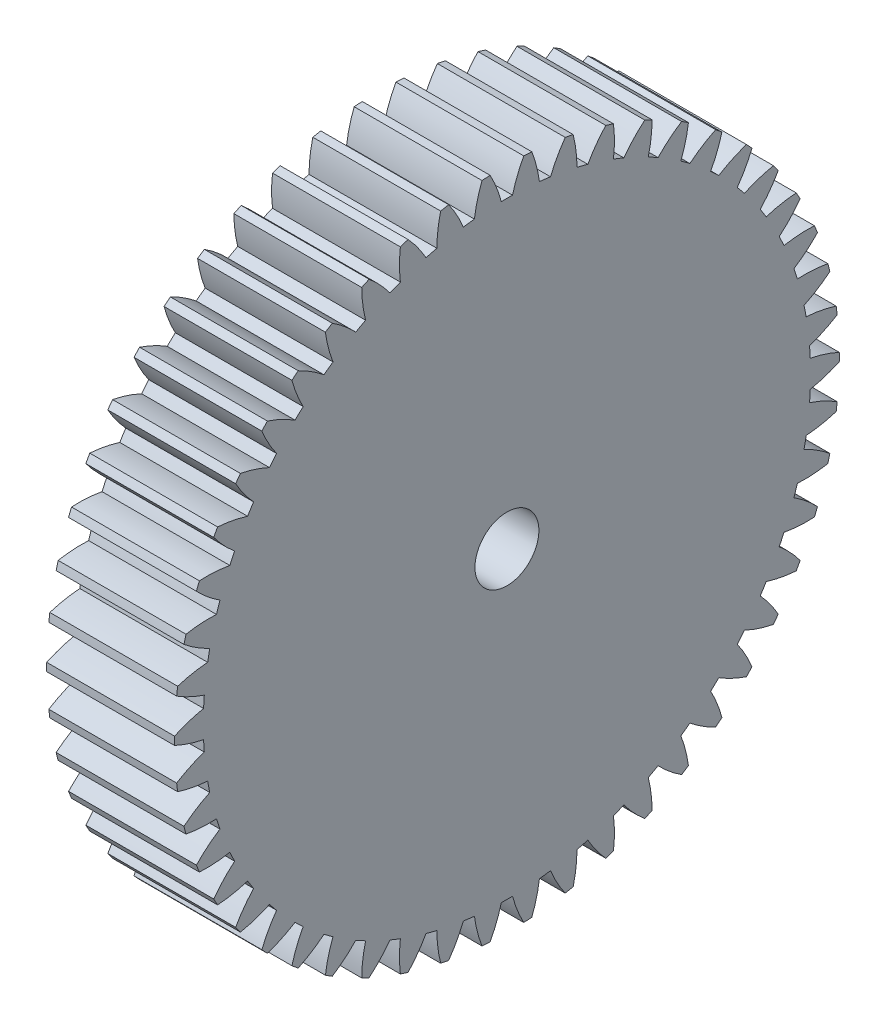
from build123d import *

# Parameters (mm, degrees)
BASPROSKE_W     = 10
BASPROSKE_H     = 26
TOOTHCUT_DEPTH  = 39.105117767
TEETHCUTS_COUNT = 50
TEETHCUTS_ANGLE = 352.8
BORSKE_R        = 2.5
BORE_DEPTH      = 50.0000508


with BuildPart() as part:
    # BasProSke → Base-Revolve (revolve)
    with BuildSketch(Plane(origin=(0, 0, 0), x_dir=(1, 0, 0), z_dir=(0, 1, 0)), mode=Mode.PRIVATE) as base_revolve_sk:
        with Locations((5, 13)):
            Rectangle(BASPROSKE_W, BASPROSKE_H)
    revolve(base_revolve_sk.sketch.rotate(Axis((-10, 0, 0), (1, 0, 0)), 180), axis=Axis((-10, 0, 0), (1, 0, 0)))

    # TooCutSke → ToothCut (cut, through all)
    with BuildSketch(Plane(origin=(0, 0, 0), x_dir=(0, 0, -1), z_dir=(1, 0, 0))):
        with BuildLine():
            ThreePointArc((0.437663408, 23.744966872), (0, 23.749), (-0.437663408, 23.744966872))
            ThreePointArc((-0.437663408, 23.744966872), (-0.815428123, 24.895236298), (-1.329433358, 25.991422664))
            ThreePointArc((-1.329433358, 25.991422664), (0, 26.0254), (1.329433358, 25.991422664))
            ThreePointArc((1.329433358, 25.991422664), (0.815428123, 24.895236298), (0.437663408, 23.744966872))
        make_face()
    toothcut = extrude(amount=TOOTHCUT_DEPTH, mode=Mode.SUBTRACT)

    # TeethCuts: ToothCut ×50 about axis
    teethcuts_axis = Axis((-10, 0, 0), (1, 0, 0))
    for i in range(1, TEETHCUTS_COUNT):
        add(toothcut.rotate(teethcuts_axis, i * TEETHCUTS_ANGLE / (TEETHCUTS_COUNT - 1)), mode=Mode.SUBTRACT)

    # BorSke → Bore (cut, symmetric)
    with BuildSketch(Plane(origin=(0, 0, 0), x_dir=(0, 0, -1), z_dir=(1, 0, 0))):
        with Locations(Location((0, 0, 0), (0, 0, 180))):
            Circle(BORSKE_R)
    extrude(amount=BORE_DEPTH, both=True, mode=Mode.SUBTRACT)


solid = part.part
